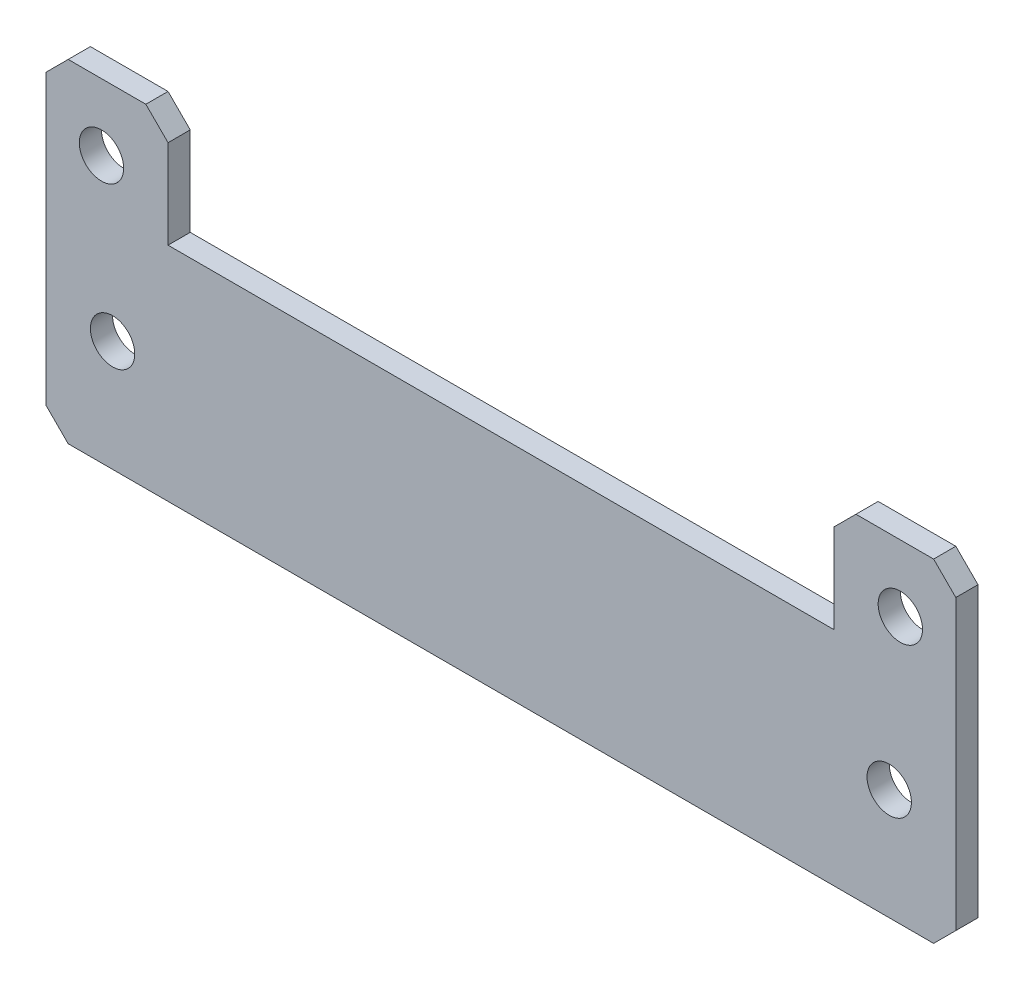
from build123d import *

# Parameters (mm, degrees)
BOSS_EXTRUDE1_DEPTH = 2
SKETCH2_R           = 2
CUT_EXTRUDE1_DEPTH  = 2
SKETCH3_R           = 2
CUT_EXTRUDE2_DEPTH  = 2


with BuildPart() as part:
    # Sketch1 → Boss-Extrude1 (new body)
    with BuildSketch(Plane.XY):
        Polygon((-41, 2), (-39, 0), (0, 0), (0, 20), (-30, 20), (-30, 28), (-32, 30), (-39, 30), (-41, 28), align=None)
        Polygon((0, 20), (0, 0), (39, 0), (41, 2), (41, 28), (39, 30), (32, 30), (30, 28), (30, 20), align=None)
    extrude(amount=BOSS_EXTRUDE1_DEPTH)

    # Sketch2 → Cut-Extrude1 (cut)
    with BuildSketch(Plane.XY.offset(2)):
        with Locations((-36, 24)):
            Circle(SKETCH2_R)
        with Locations((36, 24)):
            Circle(SKETCH2_R)
    extrude(amount=-CUT_EXTRUDE1_DEPTH, mode=Mode.SUBTRACT)

    # Sketch3 → Cut-Extrude2 (cut)
    with BuildSketch(Plane(origin=(0, 0, 0), x_dir=(-1, 0, 0), z_dir=(0, 0, -1))):
        with Locations((-35, 10)):
            Circle(SKETCH3_R)
        with Locations((35, 10)):
            Circle(SKETCH3_R)
    extrude(amount=-CUT_EXTRUDE2_DEPTH, mode=Mode.SUBTRACT)


solid = part.part
